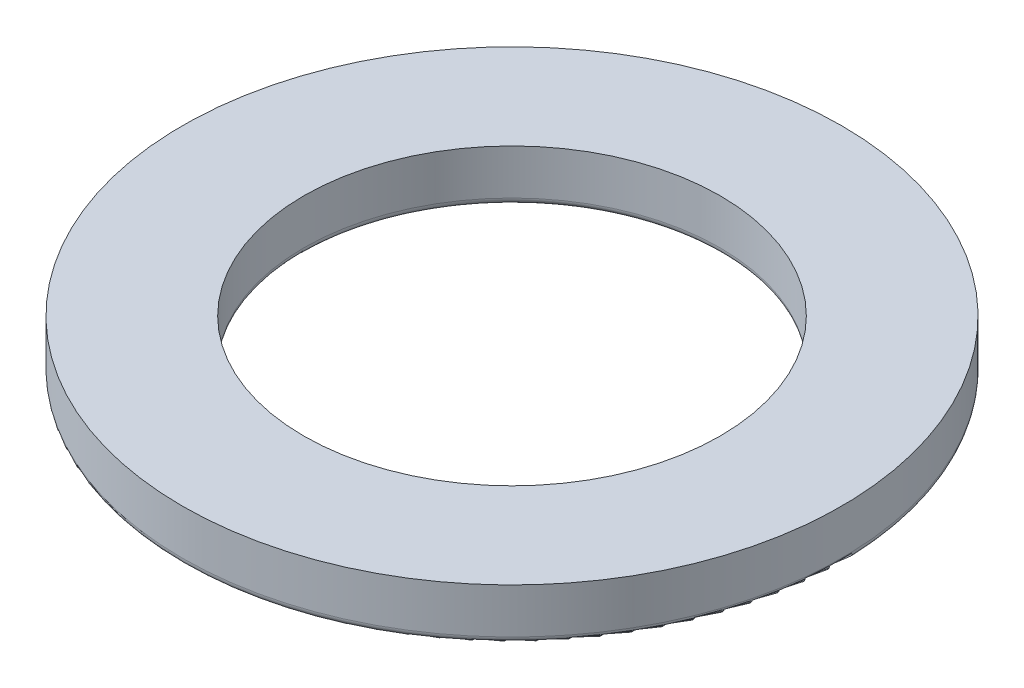
from build123d import *

# Parameters (mm, degrees)
SKETCH1_R           = 9.5
SKETCH1_R_2         = 6
BOSS_EXTRUDE1_DEPTH = 1.5
FILLET1_R           = 0.2


with BuildPart() as part:
    # Sketch1 → Boss-Extrude1 (new body)
    with BuildSketch(Plane(origin=(0, 0, 0), x_dir=(1, 0, 0), z_dir=(0, 1, 0))):
        Circle(SKETCH1_R)
        Circle(SKETCH1_R_2, mode=Mode.SUBTRACT)
    extrude(amount=BOSS_EXTRUDE1_DEPTH)

    # Fillet1
    fillet1_edges = [part.edges().sort_by_distance(p)[0] for p in [
        (-9.5, 0, 0),
        (-6, 0, 0),
    ]]
    fillet(fillet1_edges, radius=FILLET1_R)


solid = part.part
